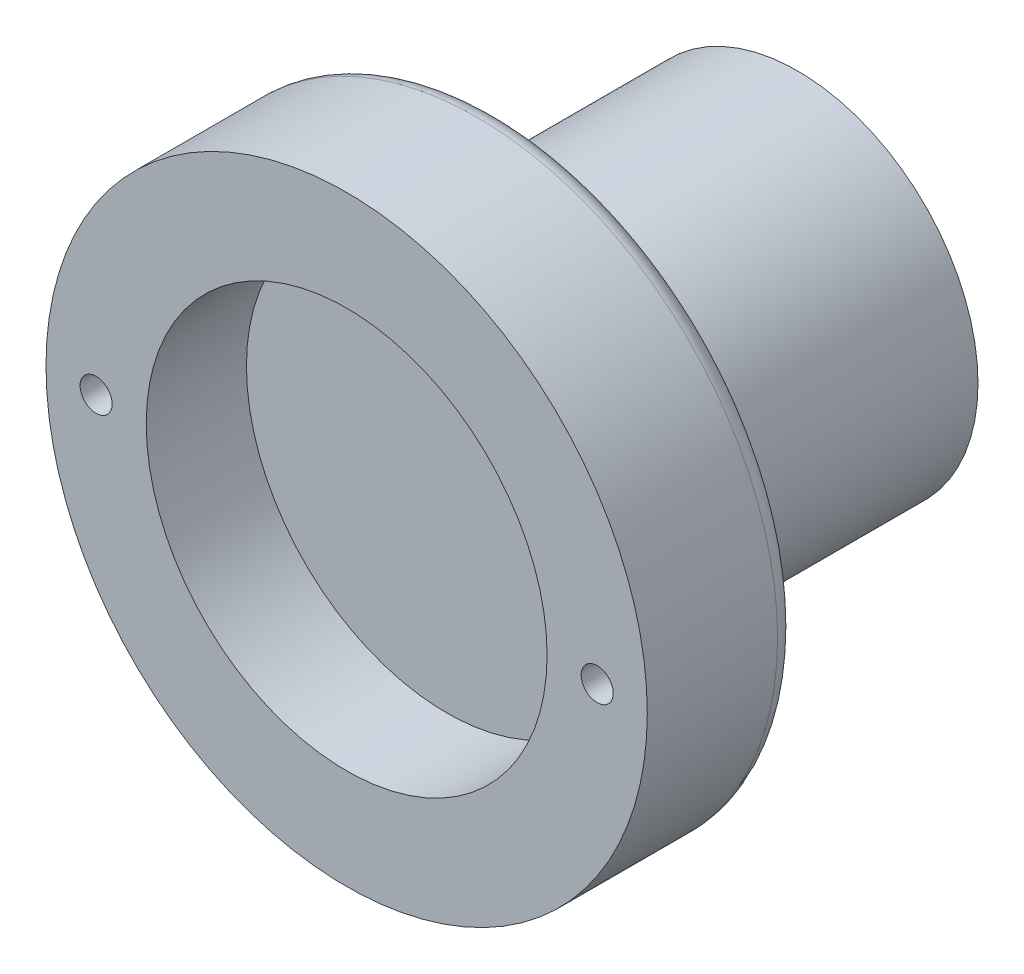
from build123d import *

# Parameters (mm, degrees)
SKETCH1_R           = 30
SKETCH1_R_2         = 1.6
BOSS_EXTRUDE1_DEPTH = 15
SKETCH2_R           = 20
CUT_EXTRUDE1_DEPTH  = 10
SKETCH3_R           = 18
BOSS_EXTRUDE2_DEPTH = 30
SKETCH4_R           = 16
CUT_EXTRUDE2_DEPTH  = 25
FILLET2_R           = 2


with BuildPart() as part:
    # Sketch1 → Boss-Extrude1 (new body)
    with BuildSketch(Plane.XY):
        Circle(SKETCH1_R)
        with Locations((-25, 0)):
            Circle(SKETCH1_R_2, mode=Mode.SUBTRACT)
        with Locations((25, 0)):
            Circle(SKETCH1_R_2, mode=Mode.SUBTRACT)
    extrude(amount=BOSS_EXTRUDE1_DEPTH)

    # Sketch2 → Cut-Extrude1 (cut)
    with BuildSketch(Plane.XY.offset(15)):
        Circle(SKETCH2_R)
    extrude(amount=-CUT_EXTRUDE1_DEPTH, mode=Mode.SUBTRACT)

    # Sketch3 → Boss-Extrude2 (add)
    with BuildSketch(Plane(origin=(0, 0, 0), x_dir=(-1, 0, 0), z_dir=(0, 0, -1))):
        Circle(SKETCH3_R)
    extrude(amount=BOSS_EXTRUDE2_DEPTH)

    # Sketch4 → Cut-Extrude2 (cut)
    with BuildSketch(Plane(origin=(0, 0, -30), x_dir=(-1, 0, 0), z_dir=(0, 0, -1))):
        Circle(SKETCH4_R)
    extrude(amount=-CUT_EXTRUDE2_DEPTH, mode=Mode.SUBTRACT)

    # Fillet2
    fillet2_edges = [part.edges().sort_by_distance(p)[0] for p in [
        (-30, 0, 0),
    ]]
    fillet(fillet2_edges, radius=FILLET2_R)


solid = part.part
